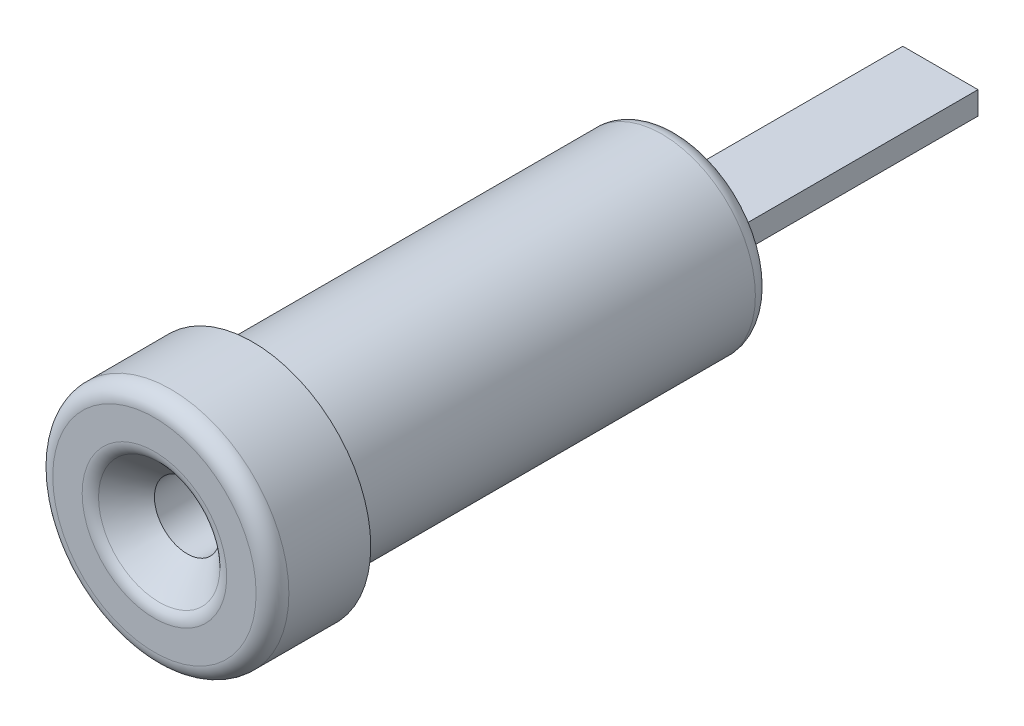
from build123d import *

# Parameters (mm, degrees)
SKETCH3_W          = 4.030508652
SKETCH3_H          = 4.030508652
SKETCH3_W_2        = 2.295648056
SKETCH3_H_2        = 0.7
CUT_EXTRUDE1_DEPTH = 8
CHAMFER1_SIZE      = 1
FILLET1_R          = 0.5


with BuildPart() as part:
    # Sketch2 → Revolve1 (revolve)
    with BuildSketch(Plane(origin=(0, 0, 0), x_dir=(0, 0, -1), z_dir=(1, 0, 0))):
        Polygon((0, 1), (12, 1), (12, 0), (24, 0), (24, 1.2), (16, 1.2), (16, 2.85), (3, 2.85), (3, 3.605), (0, 3.605), align=None)
    revolve(axis=Axis((0, 0, 0), (0, 0, -1)))

    # Sketch3 → Cut-Extrude1 (cut)
    with BuildSketch(Plane(origin=(0, 0, -24), x_dir=(-1, 0, 0), z_dir=(0, 0, -1))):
        Rectangle(SKETCH3_W, SKETCH3_H)
        Rectangle(SKETCH3_W_2, SKETCH3_H_2, mode=Mode.SUBTRACT)
    extrude(amount=-CUT_EXTRUDE1_DEPTH, mode=Mode.SUBTRACT)

    # Chamfer1
    chamfer1_edges = [part.edges().sort_by_distance(p)[0] for p in [
        (0, -1, 0),
    ]]
    chamfer(chamfer1_edges, length=CHAMFER1_SIZE)

    # Fillet1
    fillet1_edges = [part.edges().sort_by_distance(p)[0] for p in [
        (0, -2, 0),
        (0, -3.605, 0),
        (0, -2.85, -16),
    ]]
    fillet(fillet1_edges, radius=FILLET1_R)


solid = part.part
